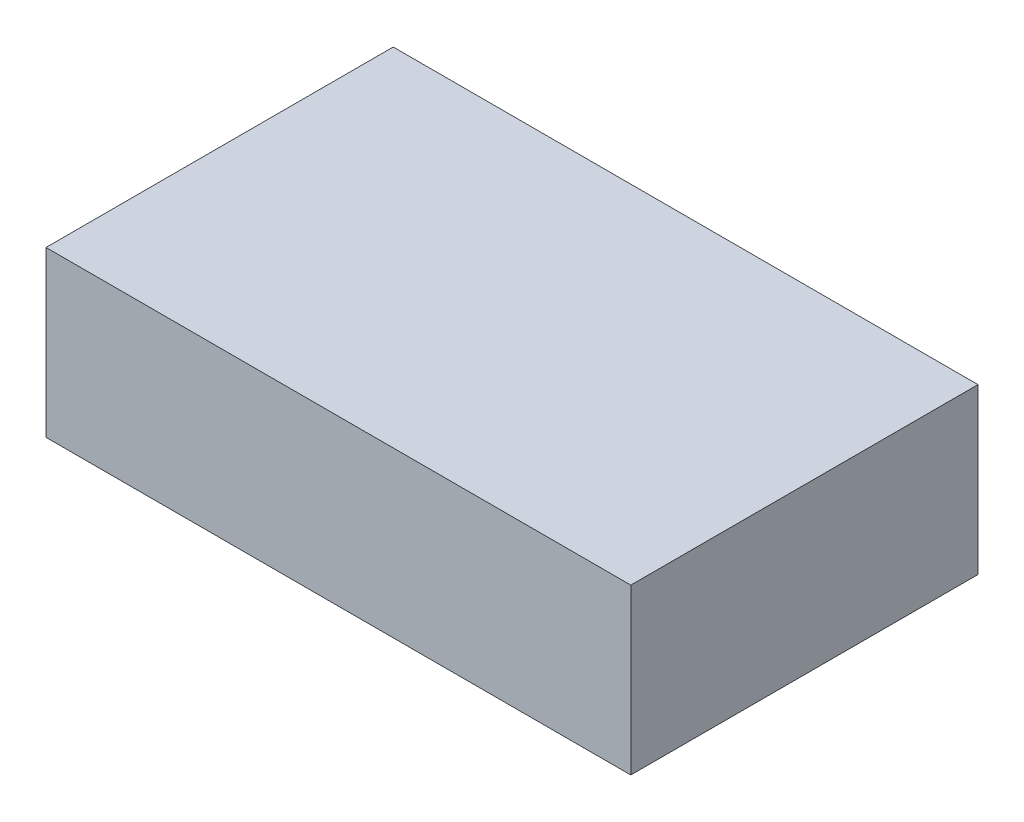
from build123d import *

# Parameters (mm, degrees)
SKETCH1_W           = 32
SKETCH1_H           = 19
BOSS_EXTRUDE1_DEPTH = 9


with BuildPart() as part:
    # Sketch1 → Boss-Extrude1 (new body)
    with BuildSketch(Plane(origin=(0, 0, 0), x_dir=(1, 0, 0), z_dir=(0, 1, 0))):
        Rectangle(SKETCH1_W, SKETCH1_H)
    extrude(amount=BOSS_EXTRUDE1_DEPTH)


solid = part.part
